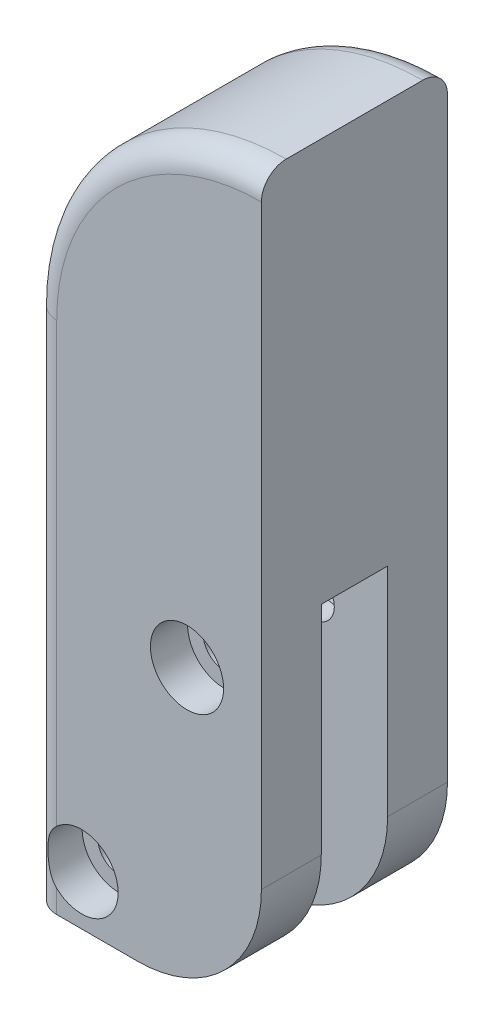
from build123d import *

# Parameters (mm, degrees)
SALIENTE_EXTRUIR1_DEPTH = 15
CROQUIS2_W              = 5.35
CROQUIS2_H              = 27.5
CORTAR_EXTRUIR1_DEPTH   = 30
CROQUIS3_R              = 1.7
CORTAR_EXTRUIR2_DEPTH   = 30
REDONDEO1_R             = 10
REDONDEO2_R             = 2
CROQUIS4_R              = 2.95
CORTAR_EXTRUIR3_DEPTH   = 3
CORTAR_EXTRUIR4_DEPTH   = 3


with BuildPart() as part:
    # Croquis1 → Saliente-Extruir1 (new body)
    with BuildSketch(Plane.XY):
        with BuildLine():
            Line((9.25, -20.75), (-9.25, -20.75))
            Line((-9.25, -20.75), (-9.25, 20.75))
            ThreePointArc((-9.25, 20.75), (-3.831475452, 33.831475452), (9.25, 39.25))
            Line((9.25, 39.25), (9.25, 20.75))
            Line((9.25, 20.75), (9.25, -20.75))
        make_face()
    extrude(amount=SALIENTE_EXTRUIR1_DEPTH)

    # Croquis2 → Cortar-Extruir1 (cut)
    with BuildSketch(Plane(origin=(9.25, 0, 0), x_dir=(0, 0, -1), z_dir=(1, 0, 0))):
        with Locations((-7.5, -7)):
            Rectangle(CROQUIS2_W, CROQUIS2_H)
    extrude(amount=-CORTAR_EXTRUIR1_DEPTH, mode=Mode.SUBTRACT)

    # Croquis3 → Cortar-Extruir2 (cut)
    with BuildSketch(Plane.XY.offset(15)):
        with Locations((3.25, 1.75)):
            Circle(CROQUIS3_R)
        with Locations((-5.25, -16.75)):
            Circle(CROQUIS3_R)
    extrude(amount=-CORTAR_EXTRUIR2_DEPTH, mode=Mode.SUBTRACT)

    # Redondeo1
    redondeo1_edges = [part.edges().sort_by_distance(p)[0] for p in [
        (9.25, -20.75, 2.4125),
        (9.25, -20.75, 12.5875),
    ]]
    fillet(redondeo1_edges, radius=REDONDEO1_R)

    # Redondeo2
    redondeo2_edges = [part.edges().sort_by_distance(p)[0] for p in [
        (-3.831475452, 33.831475452, 15),
        (-9.25, 0, 0),
        (-3.831475452, 33.831475452, 0),
        (-9.25, 0, 15),
    ]]
    fillet(redondeo2_edges, radius=REDONDEO2_R)

    # Croquis4 → Cortar-Extruir3 (cut)
    with BuildSketch(Plane.XY.offset(15)):
        with Locations((3.25, 1.75)):
            Circle(CROQUIS4_R)
        with Locations((-5.25, -16.75)):
            Circle(CROQUIS4_R)
    extrude(amount=-CORTAR_EXTRUIR3_DEPTH, mode=Mode.SUBTRACT)

    # Croquis5 → Cortar-Extruir4 (cut)
    with BuildSketch(Plane(origin=(0, 0, 0), x_dir=(-1, 0, 0), z_dir=(0, 0, -1))):
        Polygon((-0.348814897, 3.425), (-3.25, 5.1), (-6.151185103, 3.425), (-6.151185103, 0.075), (-3.25, -1.6), (-0.348814897, 0.075), align=None)
        Polygon((5.25, -13.4), (2.348814897, -15.075), (2.348814897, -18.425), (5.25, -20.1), (8.151185103, -18.425), (8.151185103, -15.075), align=None)
    extrude(amount=-CORTAR_EXTRUIR4_DEPTH, mode=Mode.SUBTRACT)


solid = part.part
